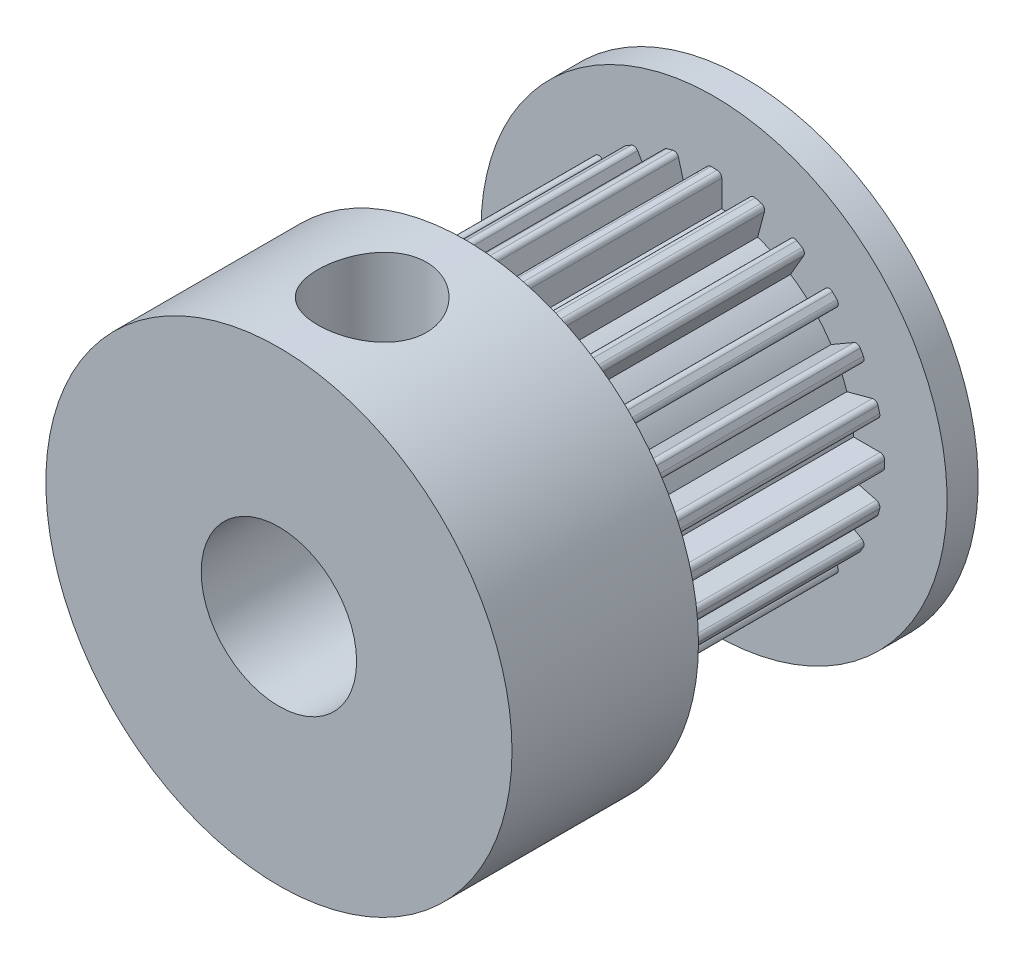
from build123d import *

# Parameters (mm, degrees)
ESQUISSE1_R             = 4.5
ESQUISSE1_R_2           = 2.5
BOSS_EXTRU_1_DEPTH      = 6
ESQUISSE1_3_R           = 7.5
ESQUISSE1_3_R_2         = 4.5
BOSS_EXTRU_2_DEPTH      = 6
ESQUISSE2_R             = 4.5
ESQUISSE2_R_2           = 2.5
BOSS_EXTRU_3_DEPTH      = 8
ESQUISSE3_R             = 4.5
ESQUISSE3_R_2           = 2.5
BOSS_EXTRU_6_DEPTH      = 1
ESQUISSE3_3_R           = 7.5
ESQUISSE3_3_R_2         = 4.5
BOSS_EXTRU_7_DEPTH      = 1
CONG_4_R                = 0.15
ENL_V_MAT_EXTRU_1_REACH = 17
ESQUISSE4_R             = 1.75


with BuildPart() as part:
    # Esquisse1 → Boss.-Extru.1 (new body)
    with BuildSketch(Plane.XY):
        Circle(ESQUISSE1_R)
        Circle(ESQUISSE1_R_2, mode=Mode.SUBTRACT)
    extrude(amount=BOSS_EXTRU_1_DEPTH)



with BuildPart() as body_2:
    # Esquisse1_3 → Boss.-Extru.2 (new body)
    with BuildSketch(Plane.XY):
        Circle(ESQUISSE1_3_R)
        Circle(ESQUISSE1_3_R_2, mode=Mode.SUBTRACT)
    extrude(amount=BOSS_EXTRU_2_DEPTH)


with BuildPart() as part_1:
    add(part.part)

    add(body_2.part)  # Boss.-Extru.3 merges body 2
    # Esquisse2 → Boss.-Extru.3 (add)
    with BuildSketch(Plane(origin=(0, 0, 0), x_dir=(-1, 0, 0), z_dir=(0, 0, -1))):
        with BuildLine():
            ThreePointArc((-1.404368416, 4.275248455), (-1.164685703, 4.346666218), (-0.921405503, 4.404657978))
            Line((-0.921405503, 4.404657978), (-1.180224548, 5.370583804))
            Line((-1.180224548, 5.370583804), (-1.663187461, 5.241174281))
            Line((-1.663187461, 5.241174281), (-1.404368416, 4.275248455))
        make_face()
        with BuildLine():
            ThreePointArc((-2.463031445, 3.766095604), (-2.25, 3.897114317), (-2.030018744, 4.016095604))
            Line((-2.030018744, 4.016095604), (-2.530018744, 4.882121008))
            Line((-2.530018744, 4.882121008), (-2.963031445, 4.632121008))
            Line((-2.963031445, 4.632121008), (-2.463031445, 3.766095604))
        make_face()
        with BuildLine():
            ThreePointArc((-3.353842952, 3.000289561), (-3.181980515, 3.181980515), (-3.000289561, 3.353842952))
            Line((-3.000289561, 3.353842952), (-3.707396343, 4.060949733))
            Line((-3.707396343, 4.060949733), (-4.060949733, 3.707396343))
            Line((-4.060949733, 3.707396343), (-3.353842952, 3.000289561))
        make_face()
        with BuildLine():
            ThreePointArc((-4.016095604, 2.030018744), (-3.897114317, 2.25), (-3.766095604, 2.463031445))
            Line((-3.766095604, 2.463031445), (-4.632121008, 2.963031445))
            Line((-4.632121008, 2.963031445), (-4.882121008, 2.530018744))
            Line((-4.882121008, 2.530018744), (-4.016095604, 2.030018744))
        make_face()
        with BuildLine():
            Line((0.25, 4.493050189), (0.25, 5.493050189))
            Line((0.25, 5.493050189), (-0.25, 5.493050189))
            Line((-0.25, 5.493050189), (-0.25, 4.493050189))
            ThreePointArc((-0.25, 4.493050189), (0, 4.5), (0.25, 4.493050189))
        make_face()
        with BuildLine():
            Line((1.180224548, 5.370583804), (0.921405503, 4.404657978))
            ThreePointArc((0.921405503, 4.404657978), (1.164685703, 4.346666218), (1.404368416, 4.275248455))
            Line((1.404368416, 4.275248455), (1.663187461, 5.241174281))
            Line((1.663187461, 5.241174281), (1.180224548, 5.370583804))
        make_face()
        with BuildLine():
            Line((2.530018744, 4.882121008), (2.030018744, 4.016095604))
            ThreePointArc((2.030018744, 4.016095604), (2.25, 3.897114317), (2.463031445, 3.766095604))
            Line((2.463031445, 3.766095604), (2.963031445, 4.632121008))
            Line((2.963031445, 4.632121008), (2.530018744, 4.882121008))
        make_face()
        with BuildLine():
            Line((3.707396343, 4.060949733), (3.000289561, 3.353842952))
            ThreePointArc((3.000289561, 3.353842952), (3.181980515, 3.181980515), (3.353842952, 3.000289561))
            Line((3.353842952, 3.000289561), (4.060949733, 3.707396343))
            Line((4.060949733, 3.707396343), (3.707396343, 4.060949733))
        make_face()
        with BuildLine():
            Line((4.632121008, 2.963031445), (3.766095604, 2.463031445))
            ThreePointArc((3.766095604, 2.463031445), (3.897114317, 2.25), (4.016095604, 2.030018744))
            Line((4.016095604, 2.030018744), (4.882121008, 2.530018744))
            Line((4.882121008, 2.530018744), (4.632121008, 2.963031445))
        make_face()
        with BuildLine():
            Line((5.241174281, 1.663187461), (4.275248455, 1.404368416))
            ThreePointArc((4.275248455, 1.404368416), (4.346666218, 1.164685703), (4.404657978, 0.921405503))
            Line((4.404657978, 0.921405503), (5.370583804, 1.180224548))
            Line((5.370583804, 1.180224548), (5.241174281, 1.663187461))
        make_face()
        with BuildLine():
            Line((5.493050189, 0.25), (4.493050189, 0.25))
            ThreePointArc((4.493050189, 0.25), (4.498262212, 0.125048291), (4.5, 0))
            ThreePointArc((4.5, 0), (4.498262212, -0.125048291), (4.493050189, -0.25))
            Line((4.493050189, -0.25), (5.493050189, -0.25))
            Line((5.493050189, -0.25), (5.493050189, 0.25))
        make_face()
        with BuildLine():
            Line((5.370583804, -1.180224548), (4.404657978, -0.921405503))
            ThreePointArc((4.404657978, -0.921405503), (4.346666218, -1.164685703), (4.275248455, -1.404368416))
            Line((4.275248455, -1.404368416), (5.241174281, -1.663187461))
            Line((5.241174281, -1.663187461), (5.370583804, -1.180224548))
        make_face()
        with BuildLine():
            Line((4.882121008, -2.530018744), (4.016095604, -2.030018744))
            ThreePointArc((4.016095604, -2.030018744), (3.897114317, -2.25), (3.766095604, -2.463031445))
            Line((3.766095604, -2.463031445), (4.632121008, -2.963031445))
            Line((4.632121008, -2.963031445), (4.882121008, -2.530018744))
        make_face()
        with BuildLine():
            Line((4.060949733, -3.707396343), (3.353842952, -3.000289561))
            ThreePointArc((3.353842952, -3.000289561), (3.181980515, -3.181980515), (3.000289561, -3.353842952))
            Line((3.000289561, -3.353842952), (3.707396343, -4.060949733))
            Line((3.707396343, -4.060949733), (4.060949733, -3.707396343))
        make_face()
        with BuildLine():
            Line((2.963031445, -4.632121008), (2.463031445, -3.766095604))
            ThreePointArc((2.463031445, -3.766095604), (2.25, -3.897114317), (2.030018744, -4.016095604))
            Line((2.030018744, -4.016095604), (2.530018744, -4.882121008))
            Line((2.530018744, -4.882121008), (2.963031445, -4.632121008))
        make_face()
        with BuildLine():
            Line((1.663187461, -5.241174281), (1.404368416, -4.275248455))
            ThreePointArc((1.404368416, -4.275248455), (1.164685703, -4.346666218), (0.921405503, -4.404657978))
            Line((0.921405503, -4.404657978), (1.180224548, -5.370583804))
            Line((1.180224548, -5.370583804), (1.663187461, -5.241174281))
        make_face()
        with BuildLine():
            ThreePointArc((0.25, -4.493050189), (0, -4.5), (-0.25, -4.493050189))
            Line((-0.25, -4.493050189), (-0.25, -5.493050189))
            Line((-0.25, -5.493050189), (0.25, -5.493050189))
            Line((0.25, -5.493050189), (0.25, -4.493050189))
        make_face()
        with BuildLine():
            ThreePointArc((-0.921405503, -4.404657978), (-1.164685703, -4.346666218), (-1.404368416, -4.275248455))
            Line((-1.404368416, -4.275248455), (-1.663187461, -5.241174281))
            Line((-1.663187461, -5.241174281), (-1.180224548, -5.370583804))
            Line((-1.180224548, -5.370583804), (-0.921405503, -4.404657978))
        make_face()
        with BuildLine():
            ThreePointArc((-2.030018744, -4.016095604), (-2.25, -3.897114317), (-2.463031445, -3.766095604))
            Line((-2.463031445, -3.766095604), (-2.963031445, -4.632121008))
            Line((-2.963031445, -4.632121008), (-2.530018744, -4.882121008))
            Line((-2.530018744, -4.882121008), (-2.030018744, -4.016095604))
        make_face()
        with BuildLine():
            ThreePointArc((-3.000289561, -3.353842952), (-3.181980515, -3.181980515), (-3.353842952, -3.000289561))
            Line((-3.353842952, -3.000289561), (-4.060949733, -3.707396343))
            Line((-4.060949733, -3.707396343), (-3.707396343, -4.060949733))
            Line((-3.707396343, -4.060949733), (-3.000289561, -3.353842952))
        make_face()
        with BuildLine():
            ThreePointArc((-3.766095604, -2.463031445), (-3.897114317, -2.25), (-4.016095604, -2.030018744))
            Line((-4.016095604, -2.030018744), (-4.882121008, -2.530018744))
            Line((-4.882121008, -2.530018744), (-4.632121008, -2.963031445))
            Line((-4.632121008, -2.963031445), (-3.766095604, -2.463031445))
        make_face()
        with BuildLine():
            ThreePointArc((-4.275248455, -1.404368416), (-4.346666218, -1.164685703), (-4.404657978, -0.921405503))
            Line((-4.404657978, -0.921405503), (-5.370583804, -1.180224548))
            Line((-5.370583804, -1.180224548), (-5.241174281, -1.663187461))
            Line((-5.241174281, -1.663187461), (-4.275248455, -1.404368416))
        make_face()
        with BuildLine():
            ThreePointArc((-4.493050189, -0.25), (-4.5, 0), (-4.493050189, 0.25))
            Line((-4.493050189, 0.25), (-5.493050189, 0.25))
            Line((-5.493050189, 0.25), (-5.493050189, -0.25))
            Line((-5.493050189, -0.25), (-4.493050189, -0.25))
        make_face()
        with BuildLine():
            ThreePointArc((-4.404657978, 0.921405503), (-4.346666218, 1.164685703), (-4.275248455, 1.404368416))
            Line((-4.275248455, 1.404368416), (-5.241174281, 1.663187461))
            Line((-5.241174281, 1.663187461), (-5.370583804, 1.180224548))
            Line((-5.370583804, 1.180224548), (-4.404657978, 0.921405503))
        make_face()
        Circle(ESQUISSE2_R)
        Circle(ESQUISSE2_R_2, mode=Mode.SUBTRACT)
    extrude(amount=BOSS_EXTRU_3_DEPTH)

    # Esquisse3 → Boss.-Extru.6 (add)
    with BuildSketch(Plane(origin=(0, 0, -8), x_dir=(-1, 0, 0), z_dir=(0, 0, -1))):
        Circle(ESQUISSE3_R)
        Circle(ESQUISSE3_R_2, mode=Mode.SUBTRACT)
    extrude(amount=BOSS_EXTRU_6_DEPTH)

    # Esquisse3_3 → Boss.-Extru.7 (add)
    with BuildSketch(Plane(origin=(0, 0, -8), x_dir=(-1, 0, 0), z_dir=(0, 0, -1))):
        Circle(ESQUISSE3_3_R)
        Circle(ESQUISSE3_3_R_2, mode=Mode.SUBTRACT)
    extrude(amount=BOSS_EXTRU_7_DEPTH)

    # Cong_4
    cong_4_edges = [part_1.edges().sort_by_distance(p)[0] for p in [
        (2.530018744, 4.882121008, -4),
        (2.963031445, 4.632121008, -4),
        (3.707396343, 4.060949733, -4),
        (4.060949733, 3.707396343, -4),
        (4.632121008, 2.963031445, -4),
        (4.882121008, 2.530018744, -4),
        (5.241174281, 1.663187461, -4),
        (5.370583804, 1.180224548, -4),
        (5.493050189, 0.25, -4),
        (5.493050189, -0.25, -4),
        (5.370583804, -1.180224548, -4),
        (5.241174281, -1.663187461, -4),
        (4.882121008, -2.530018744, -4),
        (4.632121008, -2.963031445, -4),
        (4.060949733, -3.707396343, -4),
        (3.707396343, -4.060949733, -4),
        (2.963031445, -4.632121008, -4),
        (2.530018744, -4.882121008, -4),
        (1.663187461, -5.241174281, -4),
        (1.180224548, -5.370583804, -4),
        (0.25, -5.493050189, -4),
        (-0.25, -5.493050189, -4),
        (-1.180224548, -5.370583804, -4),
        (-1.663187461, -5.241174281, -4),
        (-2.530018744, -4.882121008, -4),
        (-2.963031445, -4.632121008, -4),
        (-3.707396343, -4.060949733, -4),
        (-4.060949733, -3.707396343, -4),
        (-4.632121008, -2.963031445, -4),
        (-4.882121008, -2.530018744, -4),
        (-5.241174281, -1.663187461, -4),
        (-5.370583804, -1.180224548, -4),
        (-5.493050189, -0.25, -4),
        (-5.493050189, 0.25, -4),
        (-5.370583804, 1.180224548, -4),
        (-5.241174281, 1.663187461, -4),
        (-4.882121008, 2.530018744, -4),
        (-4.632121008, 2.963031445, -4),
        (-4.060949733, 3.707396343, -4),
        (-3.707396343, 4.060949733, -4),
        (-2.963031445, 4.632121008, -4),
        (-2.530018744, 4.882121008, -4),
        (-1.663187461, 5.241174281, -4),
        (-1.180224548, 5.370583804, -4),
        (-0.25, 5.493050189, -4),
        (0.25, 5.493050189, -4),
        (1.180224548, 5.370583804, -4),
        (1.663187461, 5.241174281, -4),
    ]]
    fillet(cong_4_edges, radius=CONG_4_R)

    # Esquisse4 → Enl_v. mat.-Extru.1 (cut, up to next)
    with BuildSketch(Plane(origin=(0, 7.5, 0), x_dir=(1, 0, 0), z_dir=(0, 1, 0)), mode=Mode.PRIVATE) as enl_v_mat_extru_1_sk1:
        with Locations((0, -3)):
            Circle(ESQUISSE4_R)
    enl_v_mat_extru_1_tool1 = extrude(enl_v_mat_extru_1_sk1.sketch, amount=-ENL_V_MAT_EXTRU_1_REACH, mode=Mode.PRIVATE) & part_1.part
    add(enl_v_mat_extru_1_tool1.solids().sort_by_distance((0, 7.5, 3))[0], mode=Mode.SUBTRACT)


solid = part_1.part
